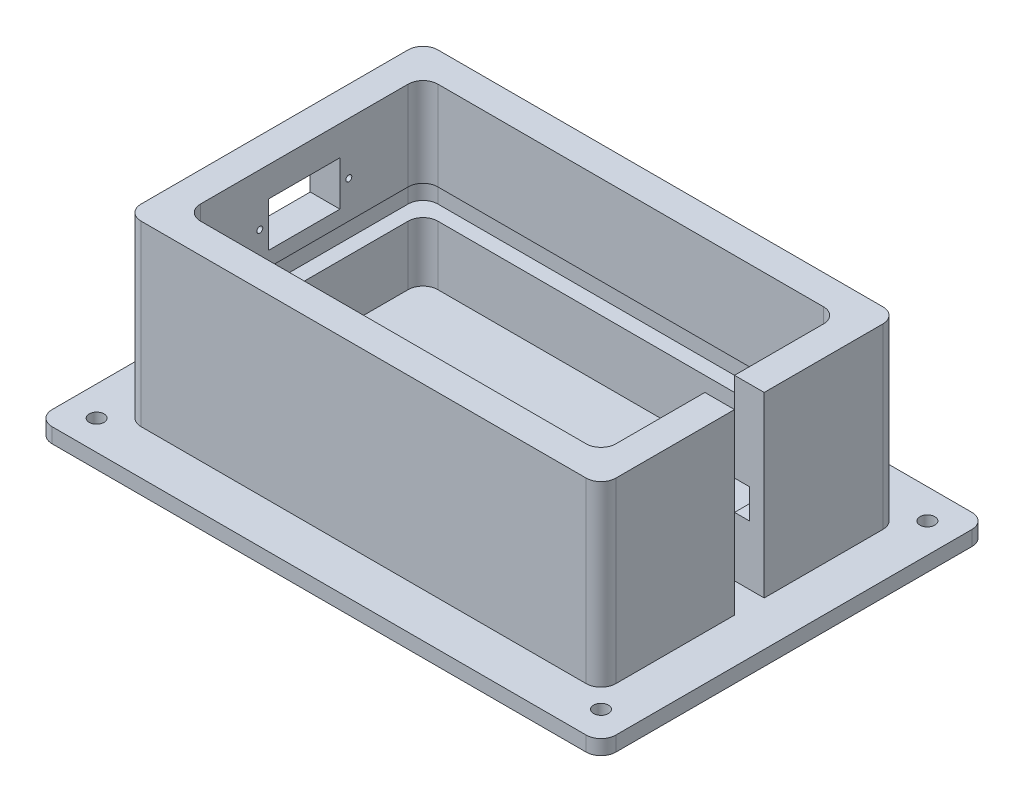
from build123d import *

# Parameters (mm, degrees)
SKETCH_1_W          = 190
SKETCH_1_H          = 130
SKETCH_1_R          = 2.5
EXTRUDE_1_DEPTH     = 5
FILLET_1_R          = 5
EXTRUDE_2_DEPTH     = 60
SKETCH_3_R          = 1
SKETCH_3_W          = 24
SKETCH_3_H          = 15
CUT_EXTRUDE_1_DEPTH = 10
CUT_EXTRUDE_2_DEPTH = 5


with BuildPart() as part:
    # 草圖1 → 填料-伸長1 (new body)
    with BuildSketch(Plane(origin=(0, 0, 0), x_dir=(1, 0, 0), z_dir=(0, 1, 0))):
        Rectangle(SKETCH_1_W, SKETCH_1_H)
        with Locations((-85, 55)):
            Circle(SKETCH_1_R, mode=Mode.SUBTRACT)
        with Locations((85, 55)):
            Circle(SKETCH_1_R, mode=Mode.SUBTRACT)
        with Locations((-85, -55)):
            Circle(SKETCH_1_R, mode=Mode.SUBTRACT)
        with Locations((85, -55)):
            Circle(SKETCH_1_R, mode=Mode.SUBTRACT)
    extrude(amount=EXTRUDE_1_DEPTH)

    # 圓角1
    fillet_1_edges = [part.edges().sort_by_distance(p)[0] for p in [
        (95, 2.5, 65),
        (-95, 2.5, 65),
        (-95, 2.5, -65),
        (95, 2.5, -65),
    ]]
    fillet(fillet_1_edges, radius=FILLET_1_R)

    # 草圖2 → 填料-伸長2 (add)
    with BuildSketch(Plane(origin=(0, 5, 0), x_dir=(1, 0, 0), z_dir=(0, 1, 0))):
        with BuildLine():
            Line((-80, 45), (-80, -45))
            ThreePointArc((-80, -45), (-78.535533906, -48.535533906), (-75, -50))
            Line((-75, -50), (75, -50))
            ThreePointArc((75, -50), (78.535533906, -48.535533906), (80, -45))
            Line((80, -45), (80, -5))
            Line((80, -5), (70, -5))
            Line((70, -5), (70, -35))
            ThreePointArc((70, -35), (68.535533906, -38.535533906), (65, -40))
            Line((65, -40), (-65, -40))
            ThreePointArc((-65, -40), (-68.535533906, -38.535533906), (-70, -35))
            Line((-70, -35), (-70, 35))
            ThreePointArc((-70, 35), (-68.535533906, 38.535533906), (-65, 40))
            Line((-65, 40), (65, 40))
            ThreePointArc((65, 40), (68.535533906, 38.535533906), (70, 35))
            Line((70, 35), (70, 5))
            Line((70, 5), (80, 5))
            Line((80, 5), (80, 45))
            ThreePointArc((80, 45), (78.535533906, 48.535533906), (75, 50))
            Line((75, 50), (-75, 50))
            ThreePointArc((-75, 50), (-78.535533906, 48.535533906), (-80, 45))
        make_face()
    extrude(amount=EXTRUDE_2_DEPTH)

    # 草圖3 → 除料-伸長1 (cut)
    with BuildSketch(Plane.ZY.offset(80)):
        with Locations((15, 47.5)):
            Circle(SKETCH_3_R)
        with Locations((-15, 47.5)):
            Circle(SKETCH_3_R)
        with Locations((0, 47.5)):
            Rectangle(SKETCH_3_W, SKETCH_3_H)
    extrude(amount=-CUT_EXTRUDE_1_DEPTH, mode=Mode.SUBTRACT)

    # 草圖4 → 除料-伸長2 (cut, symmetric)
    with BuildSketch(Plane(origin=(0, 30, 0), x_dir=(1, 0, 0), z_dir=(0, 1, 0))):
        with BuildLine():
            Line((-70, 45), (70, 45))
            ThreePointArc((70, 45), (73.535533906, 43.535533906), (75, 40))
            Line((75, 40), (75, -40))
            ThreePointArc((75, -40), (73.535533906, -43.535533906), (70, -45))
            Line((70, -45), (-70, -45))
            ThreePointArc((-70, -45), (-73.535533906, -43.535533906), (-75, -40))
            Line((-75, -40), (-75, 40))
            ThreePointArc((-75, 40), (-73.535533906, 43.535533906), (-70, 45))
        make_face()
        with BuildLine():
            Line((-65, 40), (65, 40))
            ThreePointArc((65, 40), (68.535533906, 38.535533906), (70, 35))
            Line((70, 35), (70, -35))
            ThreePointArc((70, -35), (68.535533906, -38.535533906), (65, -40))
            Line((65, -40), (-65, -40))
            ThreePointArc((-65, -40), (-68.535533906, -38.535533906), (-70, -35))
            Line((-70, -35), (-70, 35))
            ThreePointArc((-70, 35), (-68.535533906, 38.535533906), (-65, 40))
        make_face(mode=Mode.SUBTRACT)
    extrude(amount=CUT_EXTRUDE_2_DEPTH, both=True, mode=Mode.SUBTRACT)


solid = part.part
